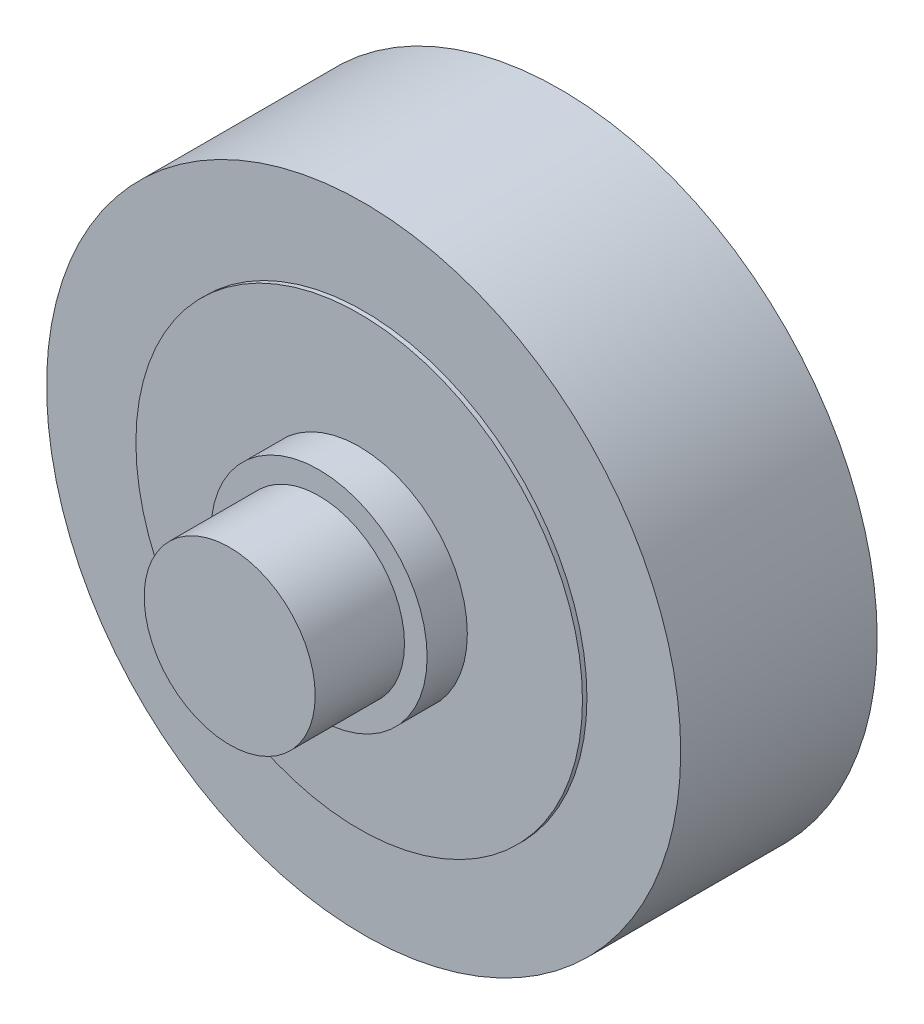
from build123d import *

# Parameters (mm, degrees)
SKETCH1_R                = 71
SKETCH1_R_2              = 50
BOSS_EXTRUDE1_DEPTH      = 44
SKETCH2_R                = 24.216288289
SKETCH2_R_2              = 19.150259362
BOSS_EXTRUDE2_DEPTH      = 54
BOSS_EXTRUDE2_DEPTH_BACK = 10
SKETCH3_R                = 19.150259362
BOSS_EXTRUDE3_DEPTH      = 30
SKETCH4_R                = 19.150259362
BOSS_EXTRUDE4_DEPTH      = 74
SKETCH7_R                = 50
BOSS_EXTRUDE5_DEPTH      = 1
BOSS_EXTRUDE5_DEPTH_BACK = 44


with BuildPart() as part:
    # Sketch1 → Boss-Extrude1 (new body)
    with BuildSketch(Plane.XY):
        Circle(SKETCH1_R)
        Circle(SKETCH1_R_2, mode=Mode.SUBTRACT)
    extrude(amount=BOSS_EXTRUDE1_DEPTH)



with BuildPart() as body_2:
    # Sketch2 → Boss-Extrude2 (new body, two sides)
    with BuildSketch(Plane.XY) as boss_extrude2_sk:
        Circle(SKETCH2_R)
        Circle(SKETCH2_R_2, mode=Mode.SUBTRACT)
    extrude(amount=BOSS_EXTRUDE2_DEPTH)
    extrude(boss_extrude2_sk.sketch, amount=-BOSS_EXTRUDE2_DEPTH_BACK)


with BuildPart() as body_3:
    # Sketch3 → Boss-Extrude3 (new body)
    with BuildSketch(Plane.XY):
        Circle(SKETCH3_R)
    extrude(amount=-BOSS_EXTRUDE3_DEPTH)


with BuildPart() as body_4:
    # Sketch4 → Boss-Extrude4 (new body)
    with BuildSketch(Plane.XY):
        Circle(SKETCH4_R)
    extrude(amount=BOSS_EXTRUDE4_DEPTH)


with BuildPart() as part_1:
    add(part.part)

    add(body_2.part)  # Boss-Extrude5 merges body 2

    add(body_3.part)  # Boss-Extrude5 merges body 3

    add(body_4.part)  # Boss-Extrude5 merges body 4
    # Sketch7 → Boss-Extrude5 (add, two sides)
    with BuildSketch(Plane.XY.offset(44)) as boss_extrude5_sk:
        Circle(SKETCH7_R)
    extrude(amount=BOSS_EXTRUDE5_DEPTH)
    extrude(boss_extrude5_sk.sketch, amount=-BOSS_EXTRUDE5_DEPTH_BACK)


solid = part_1.part
